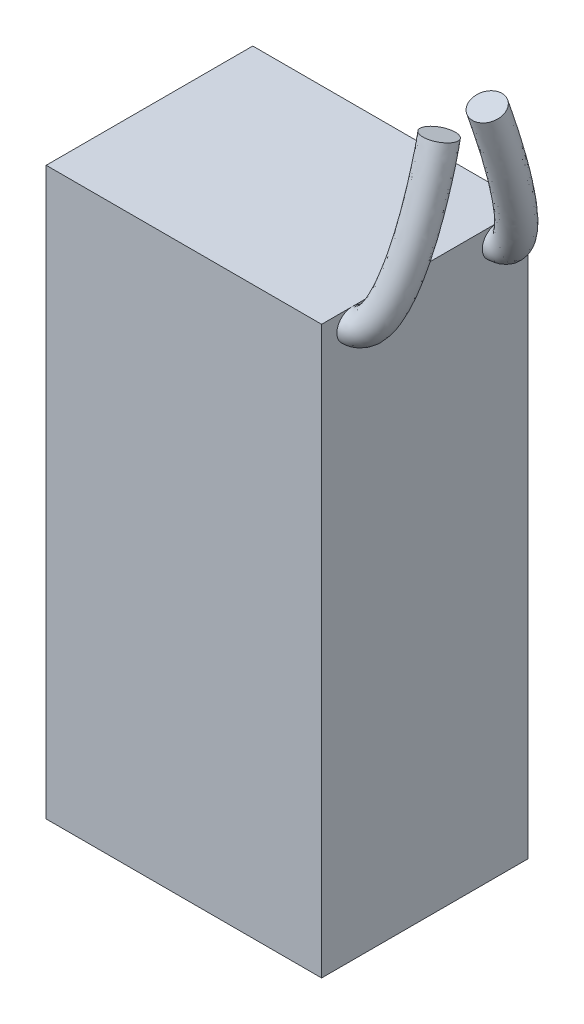
from build123d import *

# Parameters (mm, degrees)
SKETCH_1_W      = 36
SKETCH_1_H      = 27
EXTRUDE_1_DEPTH = 74
SKETCH_2_R      = 2
SKETCH_7_R      = 2


with BuildPart() as part:
    # Эскиз1 → Бобышка-Вытянуть1 (new body)
    with BuildSketch(Plane(origin=(0, 0, 0), x_dir=(1, 0, 0), z_dir=(0, 1, 0))):
        Rectangle(SKETCH_1_W, SKETCH_1_H)
    extrude(amount=EXTRUDE_1_DEPTH)

    # По траектории1: sweep along a path in Эскиз4
    with BuildLine() as sweep_1_path:  # in the path sketch's own coordinates; laid on its plane below (add() does not lay a ready-made edge on the line's plane)
        add(Edge.make_bspline(
            [(-18, -66.076411234), (-23.742943234, -66.28318966), (-23.404198894, -83.547219803), (-23, -87.819533928)],
            knots=[0, 0, 0, 0, 1, 1, 1, 1], degree=3))
    # Эскиз2 → По траектории1 (sweep)
    with BuildSketch(Plane(origin=(18, 0, 0), x_dir=(0, 0, -1), z_dir=(1, 0, 0))):
        with Locations((-9.5, 72)):
            Circle(SKETCH_2_R)
    sweep(path=Plane(origin=(0, 8.81081368, 28.818872995), x_dir=(-1, 0, 0), z_dir=(0, 0.2923717047227373, 0.9563047559630353)) * sweep_1_path.line)

    # По траектории2: sweep along a path in Эскиз6
    with BuildLine() as sweep_2_path:  # in the path sketch's own coordinates; laid on its plane below (add() does not lay a ready-made edge on the line's plane)
        add(Edge.make_bspline(
            [(-18, 66.076411234), (-21.87269918, 66.293847573), (-23.822441066, 75.687463782), (-23, 87.819533928)],
            knots=[0, 0, 0, 0, 1, 1, 1, 1], degree=3))
    # Эскиз7 → По траектории2 (sweep)
    with BuildSketch(Plane(origin=(18, 0, 0), x_dir=(0, 0, -1), z_dir=(1, 0, 0))):
        with Locations((9.5, 72)):
            Circle(SKETCH_7_R)
    sweep(path=Plane(origin=(0, 8.81081368, -28.818872995), x_dir=(-1, 0, 0), z_dir=(0, 0.2923717047227373, -0.9563047559630353)) * sweep_2_path.line)


solid = part.part
